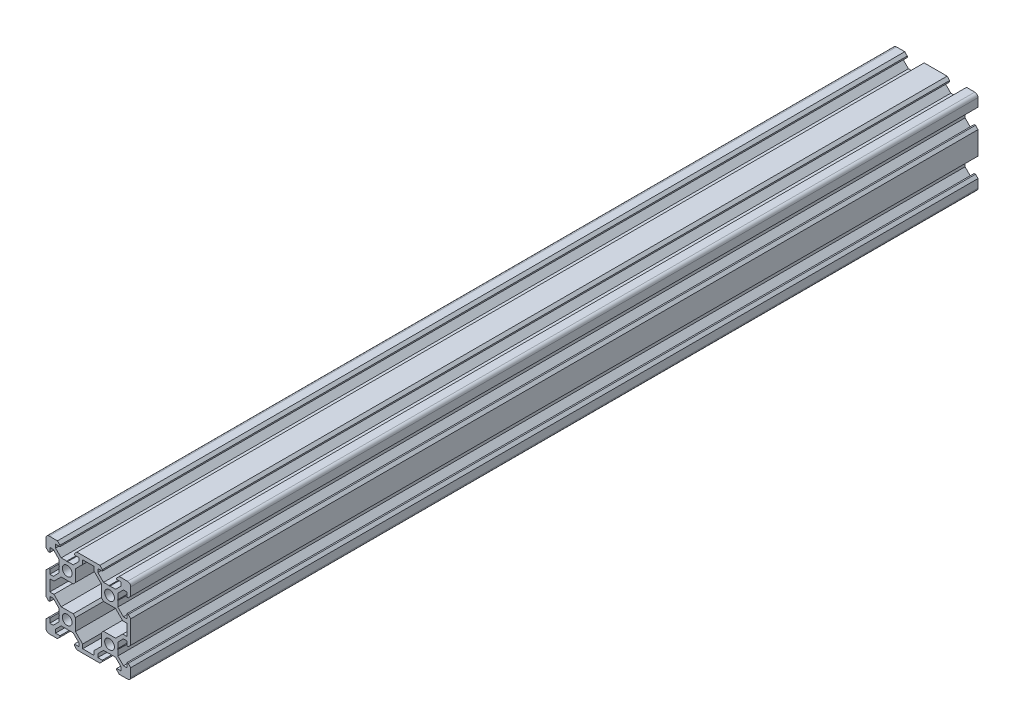
from build123d import *

# Parameters (mm, degrees)
SKETCH1_R           = 2.3
BOSS_EXTRUDE1_DEPTH = 400


with BuildPart() as part:
    # Sketch1 → Boss-Extrude1 (new body)
    with BuildSketch(Plane.XY):
        with BuildLine():
            Line((14.58, -20), (18.5, -20))
            ThreePointArc((18.5, -20), (19.560660172, -19.560660172), (20, -18.5))
            Line((20, -18.5), (20, -14.58))
            Line((20, -14.58), (18.815, -13.395))
            Line((18.815, -13.395), (18.2, -13.395))
            Line((18.2, -13.395), (18.2, -15.5))
            Line((18.2, -15.5), (16.560660172, -15.5))
            Line((16.560660172, -15.5), (13.9, -12.839339828))
            Line((13.9, -12.839339828), (13.9, -10.21))
            Line((13.9, -10.21), (13.69, -10))
            Line((13.69, -10), (13.9, -9.79))
            Line((13.9, -9.79), (13.9, -7.160660172))
            Line((13.9, -7.160660172), (16.560660172, -4.5))
            Line((16.560660172, -4.5), (18.2, -4.5))
            Line((18.2, -4.5), (18.2, -6.605))
            Line((18.2, -6.605), (18.815, -6.605))
            Line((18.815, -6.605), (20, -5.42))
            Line((20, -5.42), (20, 5.42))
            Line((20, 5.42), (18.815, 6.605))
            Line((18.815, 6.605), (18.2, 6.605))
            Line((18.2, 6.605), (18.2, 4.5))
            Line((18.2, 4.5), (16.560660172, 4.5))
            Line((16.560660172, 4.5), (13.9, 7.160660172))
            Line((13.9, 7.160660172), (13.9, 9.79))
            Line((13.9, 9.79), (13.69, 10))
            Line((13.69, 10), (13.9, 10.21))
            Line((13.9, 10.21), (13.9, 12.839339828))
            Line((13.9, 12.839339828), (16.560660172, 15.5))
            Line((16.560660172, 15.5), (18.2, 15.5))
            Line((18.2, 15.5), (18.2, 13.395))
            Line((18.2, 13.395), (18.815, 13.395))
            Line((18.815, 13.395), (20, 14.58))
            Line((20, 14.58), (20, 18.5))
            ThreePointArc((20, 18.5), (19.560660172, 19.560660172), (18.5, 20))
            Line((18.5, 20), (14.58, 20))
            Line((14.58, 20), (13.395, 18.815))
            Line((13.395, 18.815), (13.395, 18.2))
            Line((13.395, 18.2), (15.5, 18.2))
            Line((15.5, 18.2), (15.5, 16.560660172))
            Line((15.5, 16.560660172), (12.839339828, 13.9))
            Line((12.839339828, 13.9), (10.21, 13.9))
            Line((10.21, 13.9), (10, 13.69))
            Line((10, 13.69), (9.79, 13.9))
            Line((9.79, 13.9), (7.160660172, 13.9))
            Line((7.160660172, 13.9), (4.5, 16.560660172))
            Line((4.5, 16.560660172), (4.5, 18.2))
            Line((4.5, 18.2), (6.605, 18.2))
            Line((6.605, 18.2), (6.605, 18.815))
            Line((6.605, 18.815), (5.42, 20))
            Line((5.42, 20), (-5.42, 20))
            Line((-5.42, 20), (-6.605, 18.815))
            Line((-6.605, 18.815), (-6.605, 18.2))
            Line((-6.605, 18.2), (-4.5, 18.2))
            Line((-4.5, 18.2), (-4.5, 16.560660172))
            Line((-4.5, 16.560660172), (-7.160660172, 13.9))
            Line((-7.160660172, 13.9), (-9.79, 13.9))
            Line((-9.79, 13.9), (-10, 13.69))
            Line((-10, 13.69), (-10.21, 13.9))
            Line((-10.21, 13.9), (-12.839339828, 13.9))
            Line((-12.839339828, 13.9), (-15.5, 16.560660172))
            Line((-15.5, 16.560660172), (-15.5, 18.2))
            Line((-15.5, 18.2), (-13.395, 18.2))
            Line((-13.395, 18.2), (-13.395, 18.815))
            Line((-13.395, 18.815), (-14.58, 20))
            Line((-14.58, 20), (-18.5, 20))
            ThreePointArc((-18.5, 20), (-19.560660172, 19.560660172), (-20, 18.5))
            Line((-20, 18.5), (-20, 14.58))
            Line((-20, 14.58), (-18.815, 13.395))
            Line((-18.815, 13.395), (-18.2, 13.395))
            Line((-18.2, 13.395), (-18.2, 15.5))
            Line((-18.2, 15.5), (-16.560660172, 15.5))
            Line((-16.560660172, 15.5), (-13.9, 12.839339828))
            Line((-13.9, 12.839339828), (-13.9, 10.21))
            Line((-13.9, 10.21), (-13.69, 10))
            Line((-13.69, 10), (-13.9, 9.79))
            Line((-13.9, 9.79), (-13.9, 7.160660172))
            Line((-13.9, 7.160660172), (-16.560660172, 4.5))
            Line((-16.560660172, 4.5), (-18.2, 4.5))
            Line((-18.2, 4.5), (-18.2, 6.605))
            Line((-18.2, 6.605), (-18.815, 6.605))
            Line((-18.815, 6.605), (-20, 5.42))
            Line((-20, 5.42), (-20, -5.42))
            Line((-20, -5.42), (-18.815, -6.605))
            Line((-18.815, -6.605), (-18.2, -6.605))
            Line((-18.2, -6.605), (-18.2, -4.5))
            Line((-18.2, -4.5), (-16.560660172, -4.5))
            Line((-16.560660172, -4.5), (-13.9, -7.160660172))
            Line((-13.9, -7.160660172), (-13.9, -9.79))
            Line((-13.9, -9.79), (-13.69, -10))
            Line((-13.69, -10), (-13.9, -10.21))
            Line((-13.9, -10.21), (-13.9, -12.839339828))
            Line((-13.9, -12.839339828), (-16.560660172, -15.5))
            Line((-16.560660172, -15.5), (-18.2, -15.5))
            Line((-18.2, -15.5), (-18.2, -13.395))
            Line((-18.2, -13.395), (-18.815, -13.395))
            Line((-18.815, -13.395), (-20, -14.58))
            Line((-20, -14.58), (-20, -18.5))
            ThreePointArc((-20, -18.5), (-19.560660172, -19.560660172), (-18.5, -20))
            Line((-18.5, -20), (-14.58, -20))
            Line((-14.58, -20), (-13.395, -18.815))
            Line((-13.395, -18.815), (-13.395, -18.2))
            Line((-13.395, -18.2), (-15.5, -18.2))
            Line((-15.5, -18.2), (-15.5, -16.560660172))
            Line((-15.5, -16.560660172), (-12.839339828, -13.9))
            Line((-12.839339828, -13.9), (-10.21, -13.9))
            Line((-10.21, -13.9), (-10, -13.69))
            Line((-10, -13.69), (-9.79, -13.9))
            Line((-9.79, -13.9), (-7.160660172, -13.9))
            Line((-7.160660172, -13.9), (-4.5, -16.560660172))
            Line((-4.5, -16.560660172), (-4.5, -18.2))
            Line((-4.5, -18.2), (-6.605, -18.2))
            Line((-6.605, -18.2), (-6.605, -18.815))
            Line((-6.605, -18.815), (-5.42, -20))
            Line((-5.42, -20), (5.42, -20))
            Line((5.42, -20), (6.605, -18.815))
            Line((6.605, -18.815), (6.605, -18.2))
            Line((6.605, -18.2), (4.5, -18.2))
            Line((4.5, -18.2), (4.5, -16.560660172))
            Line((4.5, -16.560660172), (7.160660172, -13.9))
            Line((7.160660172, -13.9), (9.79, -13.9))
            Line((9.79, -13.9), (10, -13.69))
            Line((10, -13.69), (10.21, -13.9))
            Line((10.21, -13.9), (12.839339828, -13.9))
            Line((12.839339828, -13.9), (15.5, -16.560660172))
            Line((15.5, -16.560660172), (15.5, -18.2))
            Line((15.5, -18.2), (13.395, -18.2))
            Line((13.395, -18.2), (13.395, -18.815))
            Line((13.395, -18.815), (14.58, -20))
        make_face()
        with Locations((-10, -10)):
            Circle(SKETCH1_R, mode=Mode.SUBTRACT)
        with Locations((10, -10)):
            Circle(SKETCH1_R, mode=Mode.SUBTRACT)
        Polygon((-16.239339828, -2.7), (-18.2, -2.7), (-18.2, 2.7), (-16.239339828, 2.7), (-12.839339828, 6.1), (-7.160660172, 6.1), (-6.1, 7.160660172), (-6.1, 12.839339828), (-2.7, 16.239339828), (-2.7, 18.2), (2.7, 18.2), (2.7, 16.239339828), (6.1, 12.839339828), (6.1, 7.160660172), (7.160660172, 6.1), (12.839339828, 6.1), (16.239339828, 2.7), (18.2, 2.7), (18.2, -2.7), (16.239339828, -2.7), (12.839339828, -6.1), (7.160660172, -6.1), (6.1, -7.160660172), (6.1, -12.839339828), (2.7, -16.239339828), (2.7, -18.2), (-2.7, -18.2), (-2.7, -16.239339828), (-6.1, -12.839339828), (-6.1, -7.160660172), (-7.160660172, -6.1), (-12.839339828, -6.1), align=None, mode=Mode.SUBTRACT)
        with Locations((-10, 10)):
            Circle(SKETCH1_R, mode=Mode.SUBTRACT)
        with Locations((10, 10)):
            Circle(SKETCH1_R, mode=Mode.SUBTRACT)
    extrude(amount=BOSS_EXTRUDE1_DEPTH)


solid = part.part
